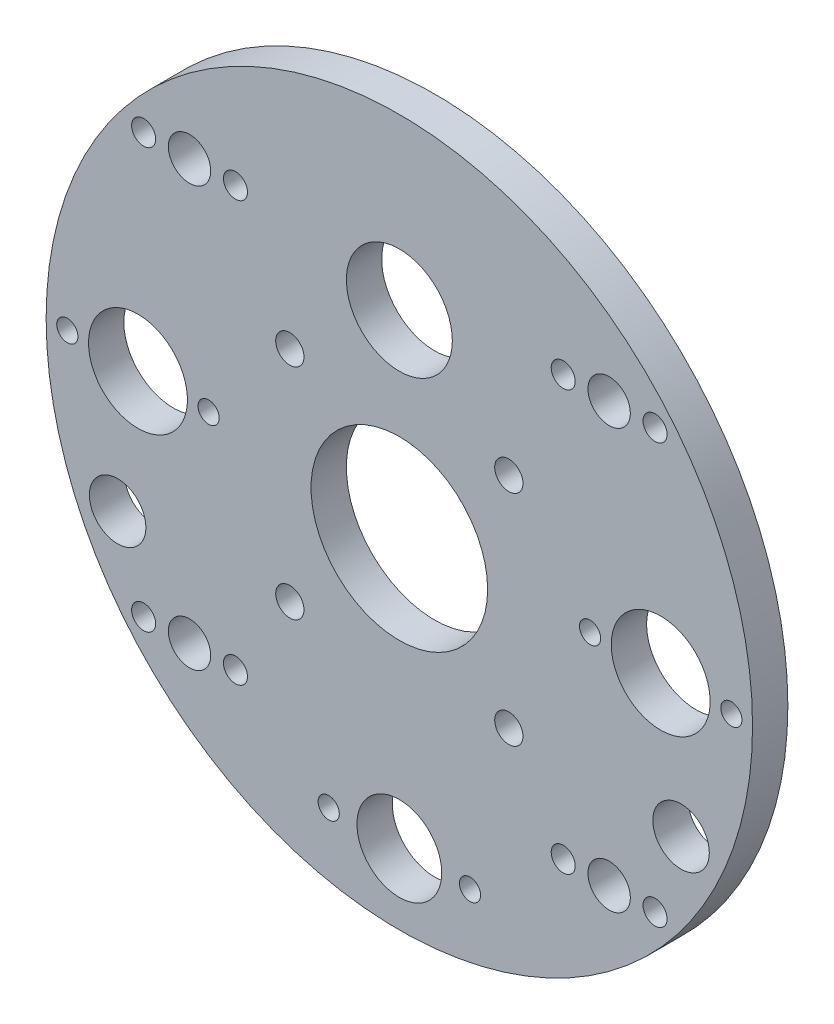
from build123d import *

# Parameters (mm, degrees)
SKETCH1_R                  = 50
BOSS_EXTRUDE1_DEPTH        = 5
F_14_0_14_DIAMETER_HOLE1_D = 14
SKETCH9_R                  = 7.5
CUT_EXTRUDE1_DEPTH         = 10
SKETCH10_R                 = 12.5
SKETCH10_R_2               = 2
CUT_EXTRUDE2_DEPTH         = 10
SKETCH11_R                 = 3
CUT_EXTRUDE3_DEPTH         = 10
CIRPATTERN1_COUNT          = 4
SKETCH12_R                 = 1.5
SKETCH12_R_2               = 6
CUT_EXTRUDE4_DEPTH         = 10
SKETCH13_R                 = 4
CUT_EXTRUDE5_DEPTH         = 10
M3_CLEARANCE_HOLE1_D       = 3.4
MIRROR2_COPY_1_D           = 3.4


with BuildPart() as part:
    # Sketch1 → Boss-Extrude1 (new body)
    with BuildSketch(Plane.XY):
        Circle(SKETCH1_R)
    extrude(amount=BOSS_EXTRUDE1_DEPTH)

    # Ø14.0 (14) Diameter Hole1 (through all)
    with Locations(Plane(origin=(0, 0, 0), x_dir=(-1, 0, 0), z_dir=(0, 0, -1))):
        with Locations((37, 0), (-37, 0)):
            Hole(F_14_0_14_DIAMETER_HOLE1_D / 2)

    # Sketch9 → Cut-Extrude1 (cut)
    with BuildSketch(Plane.XY.offset(5)):
        with Locations((0, 26)):
            Circle(SKETCH9_R)
    extrude(amount=-CUT_EXTRUDE1_DEPTH, mode=Mode.SUBTRACT)

    # Sketch10 → Cut-Extrude2 (cut)
    with BuildSketch(Plane.XY.offset(5)):
        with Locations((0, -2)):
            Circle(SKETCH10_R)
        with Locations((-15.5, 13.5)):
            Circle(SKETCH10_R_2)
        with Locations((15.5, 13.5)):
            Circle(SKETCH10_R_2)
        with Locations((15.5, -17.5)):
            Circle(SKETCH10_R_2)
        with Locations((-15.5, -17.5)):
            Circle(SKETCH10_R_2)
    extrude(amount=-CUT_EXTRUDE2_DEPTH, mode=Mode.SUBTRACT)

    # Sketch11 → Cut-Extrude3 (cut)
    with BuildSketch(Plane.XY.offset(5)):
        with Locations((-29.69848481, 29.69848481)):
            Circle(SKETCH11_R)
    cut_extrude3 = extrude(amount=-CUT_EXTRUDE3_DEPTH, mode=Mode.SUBTRACT)

    # CirPattern1: Cut-Extrude3 ×4 about axis
    cirpattern1_axis = Axis((0, 0, 0), (0, 0, 1))
    for i in range(1, CIRPATTERN1_COUNT):
        add(cut_extrude3.rotate(cirpattern1_axis, i * 360 / CIRPATTERN1_COUNT), mode=Mode.SUBTRACT)

    # Sketch12 → Cut-Extrude4 (cut)
    with BuildSketch(Plane.XY.offset(5)):
        with Locations((-47, 0)):
            Circle(SKETCH12_R)
        with Locations((-27, 0)):
            Circle(SKETCH12_R)
        with Locations((27, 0)):
            Circle(SKETCH12_R)
        with Locations((47, 0)):
            Circle(SKETCH12_R)
        with Locations((-10, -40)):
            Circle(SKETCH12_R)
        with Locations((10, -40)):
            Circle(SKETCH12_R)
        with Locations((0, -40)):
            Circle(SKETCH12_R_2)
    extrude(amount=-CUT_EXTRUDE4_DEPTH, mode=Mode.SUBTRACT)

    # Sketch13 → Cut-Extrude5 (cut)
    with BuildSketch(Plane.XY.offset(5)):
        with Locations((-39.87754263, -18.595203517)):
            Circle(SKETCH13_R)
        with Locations((39.87754263, -18.595203517)):
            Circle(SKETCH13_R)
    extrude(amount=-CUT_EXTRUDE5_DEPTH, mode=Mode.SUBTRACT)

    # M3 Clearance Hole1 (through all)
    with Locations(Plane.XY.offset(5)):
        with Locations((-36.19848481, -29.69848481), (-23.19848481, -29.69848481)):
            m3_clearance_hole1 = Hole(M3_CLEARANCE_HOLE1_D / 2)

    # Mirror1: M3 Clearance Hole1 across plane
    add(m3_clearance_hole1.mirror(Plane.ZX), mode=Mode.SUBTRACT)

    # Mirror2: M3 Clearance Hole1 across plane
    add(m3_clearance_hole1.mirror(Plane(origin=(0, 0, 0), x_dir=(0, 0, 1), z_dir=(1, 0, 0))), mode=Mode.SUBTRACT)

    # Mirror2 copy 1 (through all)
    with Locations(Plane(origin=(0, 0, 5), x_dir=(-1, 0, 0), z_dir=(0, 0, 1))):
        with Locations((-36.19848481, -29.69848481), (-23.19848481, -29.69848481)):
            Hole(MIRROR2_COPY_1_D / 2)


solid = part.part
